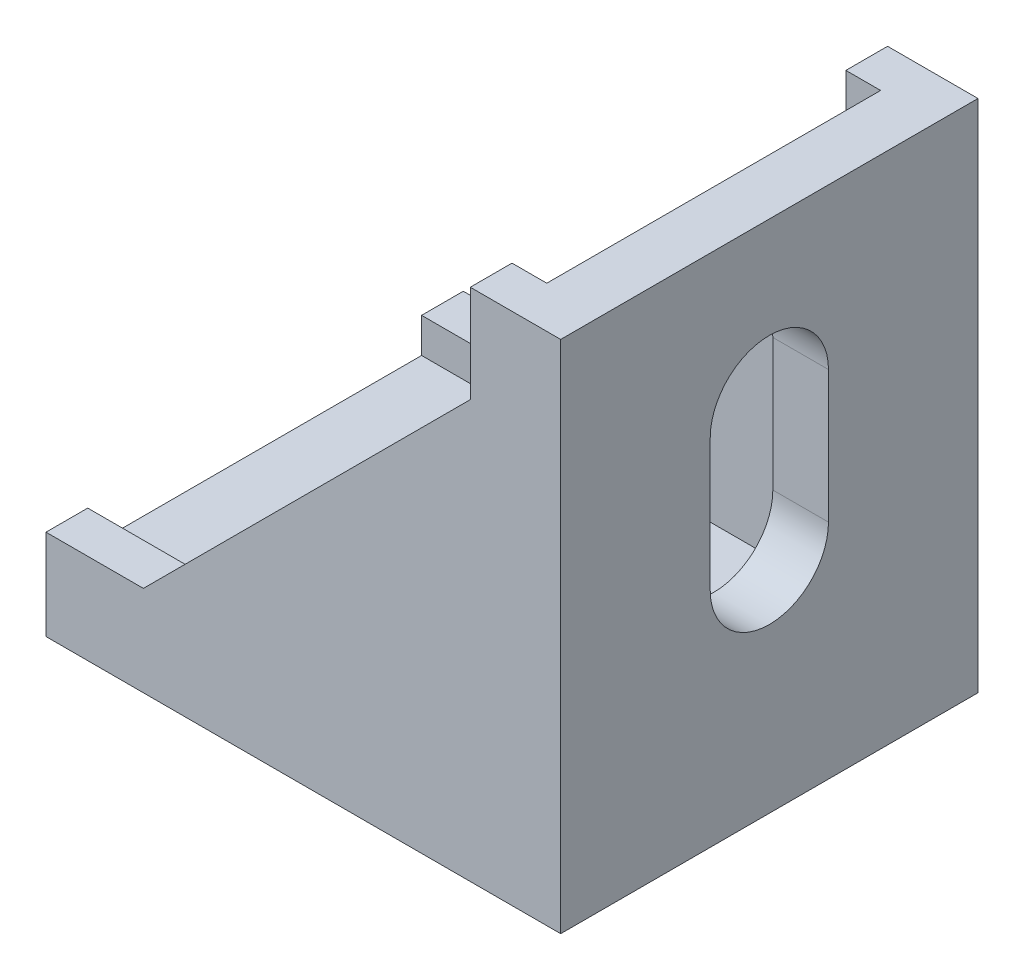
from build123d import *

# Parameters (mm, degrees)
EXTRUDE_1_DEPTH     = 30
SKETCH_3_W          = 24
SKETCH_3_H          = 35.230133155
CUT_EXTRUDE_1_DEPTH = 33
CUT_EXTRUDE_2_DEPTH = 5


with BuildPart() as part:
    # 草图1 → 凸台-拉伸1 (new body)
    with BuildSketch(Plane.XY):
        Polygon((16.339285714, 24.209821429), (9.839285714, 24.209821429), (9.839285714, 17.209821429), (-13.660714286, -6.290178571), (-20.660714286, -6.290178571), (-20.660714286, -12.790178571), (16.339285714, -12.790178571), align=None)
    extrude(amount=EXTRUDE_1_DEPTH)

    # 草图3 → 切除-拉伸1 (cut)
    with BuildSketch(Plane.ZY.offset(20.660714286)):
        with Locations((15, 8.824888007)):
            Rectangle(SKETCH_3_W, SKETCH_3_H)
    extrude(amount=-CUT_EXTRUDE_1_DEPTH, mode=Mode.SUBTRACT)

    # 草图4 → 切除-拉伸2 (cut, through all)
    with BuildSketch(Plane(origin=(0, -8.790178571, 0), x_dir=(1, 0, 0), z_dir=(0, 1, 0))):
        with BuildLine():
            Line((-9.160714286, -10.75), (0.339285714, -10.75))
            ThreePointArc((0.339285714, -10.75), (4.589285714, -15), (0.339285714, -19.25))
            Line((0.339285714, -19.25), (-9.160714286, -19.25))
            ThreePointArc((-9.160714286, -19.25), (-13.410714286, -15), (-9.160714286, -10.75))
        make_face()
    cut_extrude_2 = extrude(amount=-CUT_EXTRUDE_2_DEPTH, mode=Mode.SUBTRACT)

    # 镜向1: 切除-拉伸2 across plane
    add(cut_extrude_2.mirror(Plane(origin=(1.774553571, 1.774553571, 0), x_dir=(0, 0, 1), z_dir=(0.707106781, 0.707106781, 0))), mode=Mode.SUBTRACT)


solid = part.part
